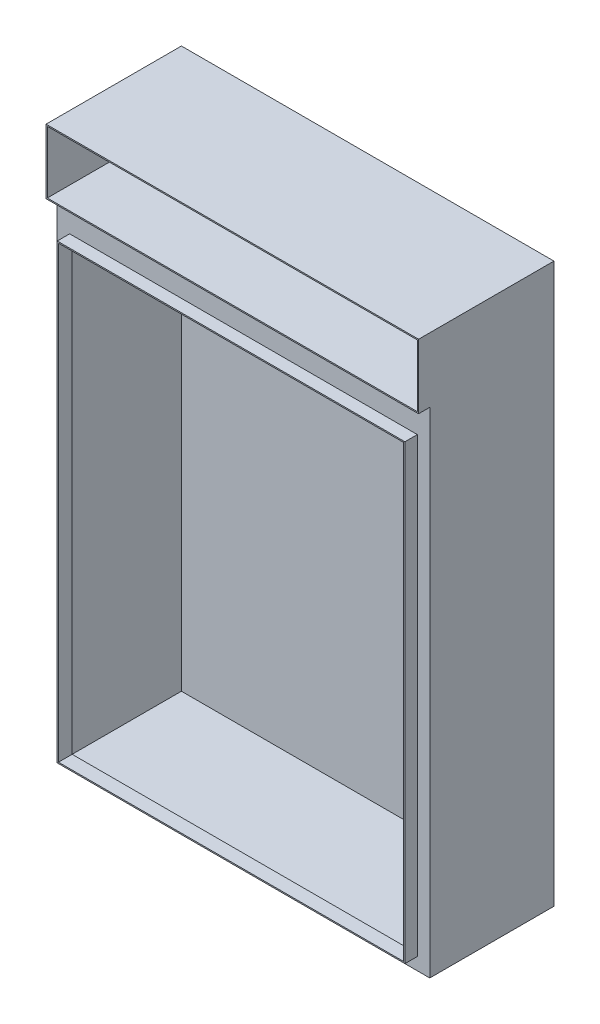
from build123d import *

# Parameters (mm, degrees)
SKETCH1_W           = 600
SKETCH1_H           = 900
BOSS_EXTRUDE1_DEPTH = 200
SHELL1_T            = -2
SKETCH2_W           = 596
SKETCH2_H           = 2
BOSS_EXTRUDE2_DEPTH = 198
SKETCH3_W           = 596
SKETCH3_H           = 794
SKETCH3_W_2         = 556
SKETCH3_H_2         = 724
BOSS_EXTRUDE3_DEPTH = 2
SKETCH4_W           = 560
SKETCH4_H           = 728
SKETCH4_W_2         = 556
SKETCH4_H_2         = 724
BOSS_EXTRUDE4_DEPTH = 20
SKETCH5_W           = 600
SKETCH5_H           = 104
SKETCH5_W_2         = 596
SKETCH5_H_2         = 100
BOSS_EXTRUDE5_DEPTH = 18


with BuildPart() as part:
    # Sketch1 → Boss-Extrude1 (new body)
    with BuildSketch(Plane.XY):
        Rectangle(SKETCH1_W, SKETCH1_H)
    extrude(amount=BOSS_EXTRUDE1_DEPTH)

    # Shell1
    shell1_openings = [part.faces().sort_by_distance(p)[0] for p in [
        (0, 0, 200),
    ]]
    offset(amount=SHELL1_T, openings=shell1_openings, kind=Kind.INTERSECTION)

    # Sketch2 → Boss-Extrude2 (add)
    with BuildSketch(Plane.XY.offset(2)):
        with Locations((0, 347)):
            Rectangle(SKETCH2_W, SKETCH2_H)
    extrude(amount=BOSS_EXTRUDE2_DEPTH)

    # Sketch3 → Boss-Extrude3 (add)
    with BuildSketch(Plane.XY.offset(200)):
        with Locations((0, -51)):
            Rectangle(SKETCH3_W, SKETCH3_H)
        with Locations((0, -66)):
            Rectangle(SKETCH3_W_2, SKETCH3_H_2, mode=Mode.SUBTRACT)
    extrude(amount=-BOSS_EXTRUDE3_DEPTH)

    # Sketch4 → Boss-Extrude4 (add)
    with BuildSketch(Plane.XY.offset(200)):
        with Locations((0, -66)):
            Rectangle(SKETCH4_W, SKETCH4_H)
        with Locations((0, -66)):
            Rectangle(SKETCH4_W_2, SKETCH4_H_2, mode=Mode.SUBTRACT)
    extrude(amount=BOSS_EXTRUDE4_DEPTH)

    # Sketch5 → Boss-Extrude5 (add)
    with BuildSketch(Plane.XY.offset(200)):
        with Locations((0, 398)):
            Rectangle(SKETCH5_W, SKETCH5_H)
        with Locations((0, 398)):
            Rectangle(SKETCH5_W_2, SKETCH5_H_2, mode=Mode.SUBTRACT)
    extrude(amount=BOSS_EXTRUDE5_DEPTH)


solid = part.part
